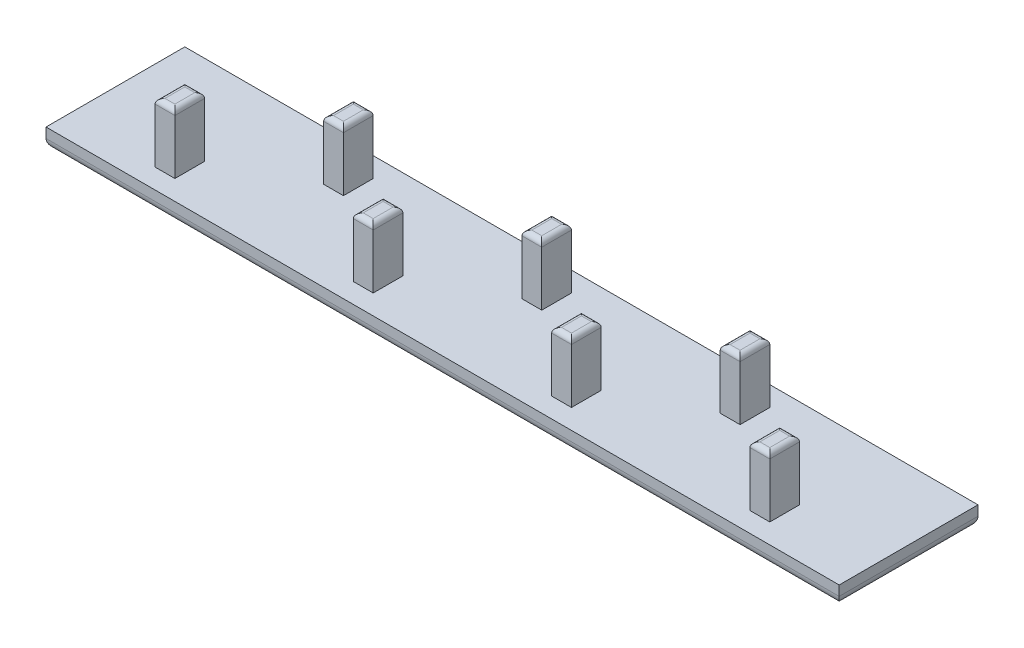
from build123d import *

# Parameters (mm, degrees)
SKETCH1_W             = 2
SKETCH1_H             = 3
BOSS_EXTRUDE1_DEPTH   = 6
BOSS_EXTRUDE1_2_DEPTH = 6
BOSS_EXTRUDE1_3_DEPTH = 6
BOSS_EXTRUDE1_4_DEPTH = 6
BOSS_EXTRUDE1_5_DEPTH = 6
BOSS_EXTRUDE1_6_DEPTH = 6
BOSS_EXTRUDE1_7_DEPTH = 6
SKETCH2_W             = 80
SKETCH2_H             = 14
BOSS_EXTRUDE2_DEPTH   = 2
FILLET1_R             = 1
FILLET2_R             = 0.5


with BuildPart() as part:
    # Sketch1 → Boss-Extrude1 (new body)
    with BuildSketch(Plane(origin=(0, 0, 0), x_dir=(1, 0, 0), z_dir=(0, 1, 0))):
        with Locations((20, 10.5)):
            Rectangle(SKETCH1_W, SKETCH1_H)
    extrude(amount=BOSS_EXTRUDE1_DEPTH)



with BuildPart() as body_2:
    # Sketch1 → Boss-Extrude1 2 (new body)
    with BuildSketch(Plane(origin=(0, 0, 0), x_dir=(1, 0, 0), z_dir=(0, 1, 0))):
        with Locations((30, 3.5)):
            Rectangle(SKETCH1_W, SKETCH1_H)
    extrude(amount=BOSS_EXTRUDE1_2_DEPTH)


with BuildPart() as body_3:
    # Sketch1 → Boss-Extrude1 3 (new body)
    with BuildSketch(Plane(origin=(0, 0, 0), x_dir=(1, 0, 0), z_dir=(0, 1, 0))):
        with Locations((40, 10.5)):
            Rectangle(SKETCH1_W, SKETCH1_H)
    extrude(amount=BOSS_EXTRUDE1_3_DEPTH)


with BuildPart() as body_4:
    # Sketch1 → Boss-Extrude1 4 (new body)
    with BuildSketch(Plane(origin=(0, 0, 0), x_dir=(1, 0, 0), z_dir=(0, 1, 0))):
        with Locations((50, 3.5)):
            Rectangle(SKETCH1_W, SKETCH1_H)
    extrude(amount=BOSS_EXTRUDE1_4_DEPTH)


with BuildPart() as body_5:
    # Sketch1 → Boss-Extrude1 5 (new body)
    with BuildSketch(Plane(origin=(0, 0, 0), x_dir=(1, 0, 0), z_dir=(0, 1, 0))):
        with Locations((60, 10.5)):
            Rectangle(SKETCH1_W, SKETCH1_H)
    extrude(amount=BOSS_EXTRUDE1_5_DEPTH)


with BuildPart() as body_6:
    # Sketch1 → Boss-Extrude1 6 (new body)
    with BuildSketch(Plane(origin=(0, 0, 0), x_dir=(1, 0, 0), z_dir=(0, 1, 0))):
        with Locations((70, 3.5)):
            Rectangle(SKETCH1_W, SKETCH1_H)
    extrude(amount=BOSS_EXTRUDE1_6_DEPTH)


with BuildPart() as body_7:
    # Sketch1 → Boss-Extrude1 7 (new body)
    with BuildSketch(Plane(origin=(0, 0, 0), x_dir=(1, 0, 0), z_dir=(0, 1, 0))):
        with Locations((10, 3.5)):
            Rectangle(SKETCH1_W, SKETCH1_H)
    extrude(amount=BOSS_EXTRUDE1_7_DEPTH)


with BuildPart() as part_1:
    add(part.part)

    add(body_2.part)  # Boss-Extrude2 merges body 2

    add(body_3.part)  # Boss-Extrude2 merges body 3

    add(body_4.part)  # Boss-Extrude2 merges body 4

    add(body_5.part)  # Boss-Extrude2 merges body 5

    add(body_6.part)  # Boss-Extrude2 merges body 6

    add(body_7.part)  # Boss-Extrude2 merges body 7
    # Sketch2 → Boss-Extrude2 (add)
    with BuildSketch(Plane.XZ):
        with Locations((40, -7)):
            Rectangle(SKETCH2_W, SKETCH2_H)
    extrude(amount=BOSS_EXTRUDE2_DEPTH)

    # Fillet1
    fillet1_edges = [part_1.edges().sort_by_distance(p)[0] for p in [
        (0, -2, -7),
        (40, -2, -14),
        (80, -2, -7),
        (40, -2, 0),
    ]]
    fillet(fillet1_edges, radius=FILLET1_R)

    # Fillet2
    fillet2_edges = [part_1.edges().sort_by_distance(p)[0] for p in [
        (20, 6, -9),
        (51, 6, -3.5),
        (50, 6, -5),
        (49, 6, -3.5),
        (50, 6, -2),
        (61, 6, -10.5),
        (60, 6, -12),
        (59, 6, -10.5),
        (60, 6, -9),
        (71, 6, -3.5),
        (70, 6, -5),
        (69, 6, -3.5),
        (70, 6, -2),
        (10, 6, -5),
        (11, 6, -3.5),
        (9, 6, -3.5),
        (10, 6, -2),
        (21, 6, -10.5),
        (20, 6, -12),
        (19, 6, -10.5),
        (31, 6, -3.5),
        (30, 6, -5),
        (29, 6, -3.5),
        (30, 6, -2),
        (41, 6, -10.5),
        (40, 6, -12),
        (39, 6, -10.5),
        (40, 6, -9),
    ]]
    fillet(fillet2_edges, radius=FILLET2_R)


solid = part_1.part
